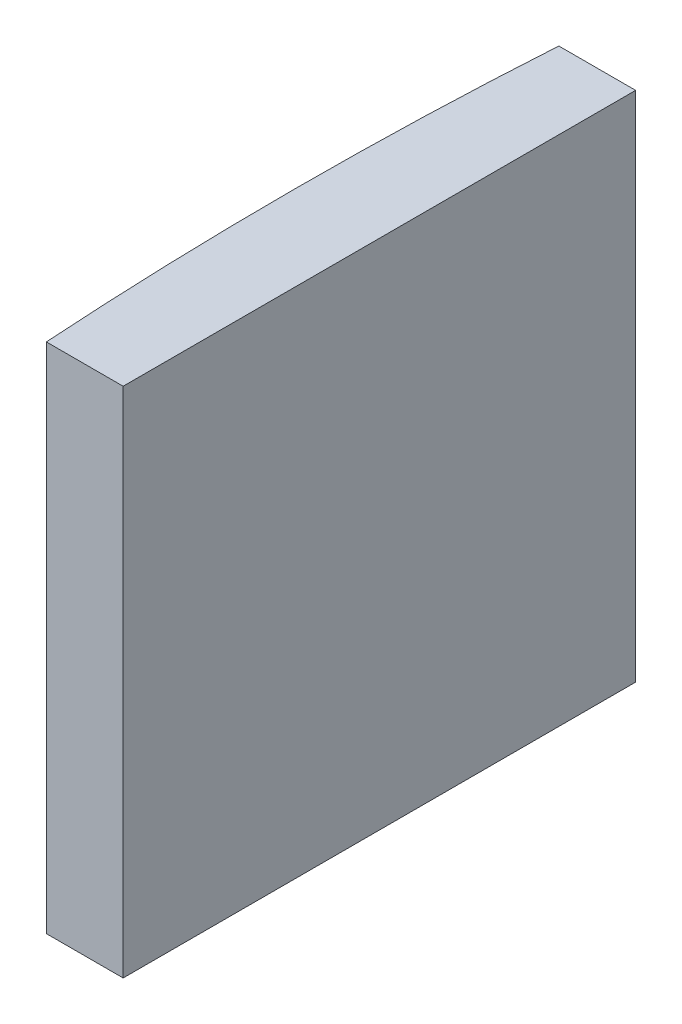
from build123d import *

# Parameters (mm, degrees)
EXTRUDE_1_DEPTH = 20


with BuildPart() as part:
    # 草图1 → 凸台-拉伸1 (new body)
    with BuildSketch(Plane(origin=(0, 0, 0), x_dir=(1, 0, 0), z_dir=(0, 1, 0))):
        with BuildLine():
            Line((-150.422087281, 10), (-147.424795665, 10))
            Line((-147.424795665, 10), (-147.424795665, -10))
            Line((-147.424795665, -10), (-150.422087281, -10))
            ThreePointArc((-150.422087281, -10), (-150.744795665, 0), (-150.422087281, 10))
        make_face()
    extrude(amount=EXTRUDE_1_DEPTH)


solid = part.part
